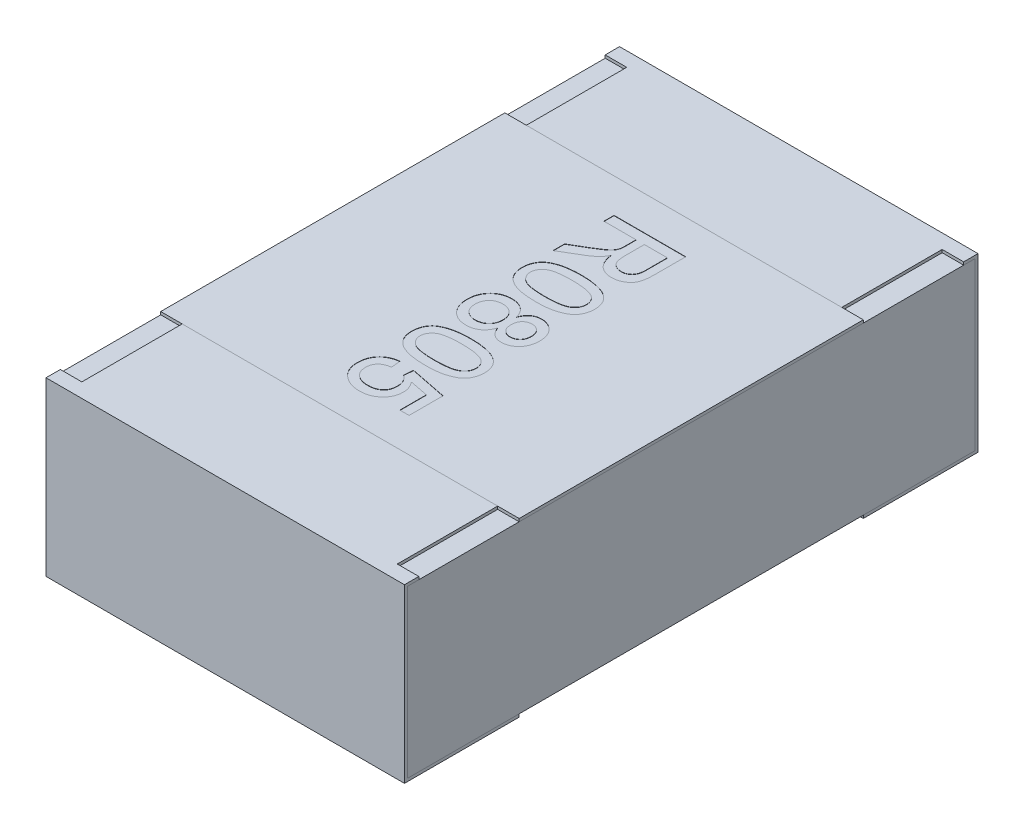
from build123d import *

# Parameters (mm, degrees)
BOSS_EXTRUDE2_DEPTH   = 0.625
BOSS_EXTRUDE2_2_DEPTH = 0.625
BOSS_EXTRUDE3_START   = -0.625
SKETCH5_W             = 1.98
SKETCH5_H             = 0.58
BOSS_EXTRUDE3_DEPTH   = 1.25
SKETCH6_W             = 0.075
SKETCH6_H             = 0.35
CUT_EXTRUDE1_DEPTH    = 0.01
SKETCH7_W             = 1.25
SKETCH7_H             = 1.2
BOSS_EXTRUDE4_DEPTH   = 0.01
TEXT0805_DEPTH        = 0.001


with BuildPart() as part:
    # Sketch4 → Boss-Extrude2 (new body, symmetric)
    with BuildSketch(Plane(origin=(0, 0, 0), x_dir=(0, 0, -1), z_dir=(1, 0, 0))):
        Polygon((-1, 0.3), (-1, -0.3), (-0.6, -0.3), (-0.6, -0.29), (-0.99, -0.29), (-0.99, 0.29), (-0.6, 0.29), (-0.6, 0.3), align=None)
    extrude(amount=BOSS_EXTRUDE2_DEPTH, both=True)


with BuildPart() as body_2:
    # Sketch4 → Boss-Extrude2 2 (new body, symmetric)
    with BuildSketch(Plane(origin=(0, 0, 0), x_dir=(0, 0, -1), z_dir=(1, 0, 0))):
        Polygon((0.6, 0.3), (1, 0.3), (1, -0.3), (0.6, -0.3), (0.6, -0.29), (0.99, -0.29), (0.99, 0.29), (0.6, 0.29), align=None)
    extrude(amount=BOSS_EXTRUDE2_2_DEPTH, both=True)


with BuildPart() as body_3:
    # Sketch5 → Boss-Extrude3 (new body)
    with BuildSketch(Plane(origin=(0, 0, 0), x_dir=(0, 0, -1), z_dir=(1, 0, 0)).offset(BOSS_EXTRUDE3_START)):
        Rectangle(SKETCH5_W, SKETCH5_H)
    extrude(amount=BOSS_EXTRUDE3_DEPTH)


with BuildPart() as cut_extrude1_tool:
    # Sketch6 → Cut-Extrude1 (new body)
    with BuildSketch(Plane(origin=(0, 0.3, 0), x_dir=(1, 0, 0), z_dir=(0, 1, 0))):
        with Locations((-0.5875, 0.775)):
            Rectangle(SKETCH6_W, SKETCH6_H)
        with Locations((0.5875, 0.775)):
            Rectangle(SKETCH6_W, SKETCH6_H)
        with Locations((0.5875, -0.775)):
            Rectangle(SKETCH6_W, SKETCH6_H)
        with Locations((-0.5875, -0.775)):
            Rectangle(SKETCH6_W, SKETCH6_H)
    extrude(amount=-CUT_EXTRUDE1_DEPTH)


with BuildPart() as part_1:
    add(part.part)

    # Cut-Extrude1: cut by cut_extrude1_tool
    add(cut_extrude1_tool.part, mode=Mode.SUBTRACT)


with BuildPart() as body_2_1:
    add(body_2.part)

    # Cut-Extrude1: cut by cut_extrude1_tool
    add(cut_extrude1_tool.part, mode=Mode.SUBTRACT)


with BuildPart() as body_4:
    # Sketch7 → Boss-Extrude4 (new body)
    with BuildSketch(Plane(origin=(0, 0.29, 0), x_dir=(1, 0, 0), z_dir=(0, 1, 0))):
        Rectangle(SKETCH7_W, SKETCH7_H)
    extrude(amount=BOSS_EXTRUDE4_DEPTH)

    # Sketch11 → TEXT0805 (cut)
    with BuildSketch(Plane(origin=(0, 0.3, 0), x_dir=(1, 0, 0), z_dir=(0, 1, 0))):
        with BuildLine():
            Line((-0.125, 0.480769231), (0.125, 0.480769231))
            Line((0.125, 0.480769231), (0.125, 0.372295673))
            add(Edge.make_bspline(
                [(0.125, 0.372295673), (0.124980081, 0.369741441), (0.124941531, 0.364798023), (0.124666062, 0.357629245), (0.124080828, 0.35095372), (0.123427193, 0.344729375), (0.122462088, 0.338966862), (0.121329846, 0.333663434), (0.119991666, 0.328839433), (0.118409887, 0.324458146), (0.116620913, 0.320392954), (0.114412437, 0.316625839), (0.111996411, 0.312995345), (0.109134976, 0.309645092), (0.106058159, 0.306428428), (0.102613855, 0.303455274), (0.098850706, 0.300711119), (0.093470755, 0.297325077), (0.08626914, 0.29376219), (0.077100416, 0.290721274), (0.067489381, 0.288777065), (0.060923489, 0.288567742), (0.057592147, 0.288461538)],
                knots=[0, 0, 0, 0, 7.663e-06, 1.4831e-05, 2.1514e-05, 2.7763e-05, 3.3601e-05, 3.9033e-05, 4.4027e-05, 4.8605e-05, 5.2999e-05, 5.7328e-05, 6.169e-05, 6.6063e-05, 7.0525e-05, 7.5034e-05, 7.9691e-05, 8.4485e-05, 9.4093e-05, 0.000103706, 0.0001134, 0.000123384, 0.000123384, 0.000123384, 0.000123384], degree=3))
            add(Edge.make_bspline(
                [(0.057592147, 0.288461538), (0.055453608, 0.288510459), (0.051229845, 0.288607082), (0.045019776, 0.289347208), (0.039086331, 0.290686435), (0.033377426, 0.292403638), (0.027974382, 0.294754309), (0.022765219, 0.297476233), (0.017899082, 0.300853001), (0.013213949, 0.304623586), (0.008918939, 0.309007151), (0.004956325, 0.313886761), (0.00153273, 0.319385225), (-0.001543983, 0.325401364), (-0.004236318, 0.331946092), (-0.006500007, 0.339062932), (-0.008272241, 0.346726684), (-0.009159985, 0.352041307), (-0.009615385, 0.354767628)],
                knots=[0, 0, 0, 0, 6.415e-06, 1.267e-05, 1.8722e-05, 2.4646e-05, 3.0525e-05, 3.6372e-05, 4.2248e-05, 4.8263e-05, 5.4389e-05, 6.0623e-05, 6.7083e-05, 7.378e-05, 8.0876e-05, 8.8288e-05, 9.616e-05, 0.000104451, 0.000104451, 0.000104451, 0.000104451], degree=3))
            add(Edge.make_bspline(
                [(-0.009615385, 0.354767628), (-0.010628144, 0.352752444), (-0.012544934, 0.348938421), (-0.015622195, 0.343677633), (-0.018667496, 0.339160094), (-0.020894326, 0.336554387), (-0.021935096, 0.335336538)],
                knots=[0, 0, 0, 0, 6.764e-06, 1.2802e-05, 1.8276e-05, 2.3078e-05, 2.3078e-05, 2.3078e-05, 2.3078e-05], degree=3))
            add(Edge.make_bspline(
                [(-0.021935096, 0.335336538), (-0.024247011, 0.332970873), (-0.028988368, 0.328119282), (-0.037139182, 0.321498652), (-0.046102745, 0.314947618), (-0.052634659, 0.311014514), (-0.055989583, 0.308994391)],
                knots=[0, 0, 0, 0, 9.916e-06, 2.0335e-05, 3.1455e-05, 4.3197e-05, 4.3197e-05, 4.3197e-05, 4.3197e-05], degree=3))
            Line((-0.055989583, 0.308994391), (-0.125, 0.267978766))
            Line((-0.125, 0.267978766), (-0.125, 0.308393429))
            Line((-0.125, 0.308393429), (-0.072215545, 0.339543269))
            add(Edge.make_bspline(
                [(-0.072215545, 0.339543269), (-0.07036357, 0.340663307), (-0.066774747, 0.342833757), (-0.061532932, 0.345968138), (-0.056708859, 0.349044075), (-0.052156321, 0.351887635), (-0.047993688, 0.354650924), (-0.044096778, 0.357178765), (-0.04061964, 0.359665648), (-0.036431824, 0.362557924), (-0.031873711, 0.366044983), (-0.027220525, 0.370141683), (-0.023421074, 0.373942975), (-0.019750609, 0.37869891), (-0.016330481, 0.384600378), (-0.014741028, 0.389606326), (-0.013972356, 0.392027244)],
                knots=[0, 0, 0, 0, 6.493e-06, 1.2582e-05, 1.8321e-05, 2.3656e-05, 2.8684e-05, 3.331e-05, 3.7589e-05, 4.1507e-05, 4.8579e-05, 5.4788e-05, 6.01e-05, 6.4668e-05, 7.2787e-05, 8.039e-05, 8.039e-05, 8.039e-05, 8.039e-05], degree=3))
            add(Edge.make_bspline(
                [(-0.013972356, 0.392027244), (-0.013789104, 0.393043422), (-0.013370736, 0.395363386), (-0.013097499, 0.399302681), (-0.012807494, 0.40407562), (-0.012815944, 0.407534649), (-0.012820513, 0.409405048)],
                knots=[0, 0, 0, 0, 3.096e-06, 7.067e-06, 1.1832e-05, 1.7441e-05, 1.7441e-05, 1.7441e-05, 1.7441e-05], degree=3))
            Line((-0.012820513, 0.409405048), (-0.012820513, 0.445512821))
            Line((-0.012820513, 0.445512821), (-0.125, 0.445512821))
            Line((-0.125, 0.445512821), (-0.125, 0.480769231))
        make_face()
        with BuildLine():
            Line((0.016025641, 0.445512821), (0.016025641, 0.378555689))
            add(Edge.make_bspline(
                [(0.016025641, 0.378555689), (0.016078383, 0.375198249), (0.016176978, 0.36892183), (0.017012973, 0.360144602), (0.018356033, 0.352650855), (0.0202836, 0.346300716), (0.022971837, 0.340968548), (0.026311873, 0.336387714), (0.030375799, 0.332490712), (0.03504878, 0.329305788), (0.04014749, 0.326797262), (0.045541227, 0.32508479), (0.051113312, 0.323891721), (0.054914825, 0.323776386), (0.056840946, 0.323717949)],
                knots=[0, 0, 0, 0, 1.0071e-05, 1.8826e-05, 2.6419e-05, 3.2881e-05, 3.8659e-05, 4.4248e-05, 4.9809e-05, 5.5463e-05, 6.1152e-05, 6.679e-05, 7.2407e-05, 7.8177e-05, 7.8177e-05, 7.8177e-05, 7.8177e-05], degree=3))
            add(Edge.make_bspline(
                [(0.056840946, 0.323717949), (0.058244232, 0.323764481), (0.060992858, 0.323855623), (0.065027077, 0.324333421), (0.068860518, 0.325262373), (0.072513445, 0.326489052), (0.075959102, 0.328128144), (0.079224189, 0.330075319), (0.082290611, 0.332398899), (0.085167707, 0.335060427), (0.087785584, 0.338116345), (0.090044243, 0.341606921), (0.091963617, 0.345504626), (0.09348696, 0.34981399), (0.094705386, 0.354521438), (0.095515966, 0.359653769), (0.096102499, 0.365187511), (0.096136411, 0.369022073), (0.096153846, 0.37099359)],
                knots=[0, 0, 0, 0, 4.211e-06, 8.249e-06, 1.216e-05, 1.6025e-05, 1.9788e-05, 2.3585e-05, 2.7411e-05, 3.1309e-05, 3.5323e-05, 3.9448e-05, 4.3749e-05, 4.8327e-05, 5.3137e-05, 5.8315e-05, 6.3901e-05, 6.9813e-05, 6.9813e-05, 6.9813e-05, 6.9813e-05], degree=3))
            Line((0.096153846, 0.37099359), (0.096153846, 0.445512821))
            Line((0.096153846, 0.445512821), (0.016025641, 0.445512821))
        make_face(mode=Mode.SUBTRACT)
        with BuildLine():
            add(Edge.make_bspline(
                [(-0.001702724, 0.243589744), (0.001870005, 0.243557452), (0.008867478, 0.243494206), (0.019106037, 0.243101913), (0.028829172, 0.242417), (0.038028443, 0.241394619), (0.0467246, 0.240183911), (0.05490528, 0.238610044), (0.062588678, 0.23683901), (0.069767331, 0.234714807), (0.076501073, 0.23237856), (0.082785669, 0.229736596), (0.088583945, 0.226737904), (0.094053366, 0.223652887), (0.098937729, 0.220061138), (0.103546409, 0.216418673), (0.107616333, 0.212352956), (0.111280719, 0.208057355), (0.114513306, 0.20346068), (0.117302904, 0.198589331), (0.119765846, 0.1934615), (0.121619965, 0.187979605), (0.12313146, 0.182257408), (0.124243336, 0.176250875), (0.124898824, 0.169953383), (0.124965894, 0.165649933), (0.125, 0.163461538)],
                knots=[0, 0, 0, 0, 1.0718e-05, 2.0992e-05, 3.0733e-05, 3.9952e-05, 4.8756e-05, 5.7065e-05, 6.4937e-05, 7.2401e-05, 7.9512e-05, 8.6312e-05, 9.2829e-05, 9.9091e-05, 0.000105122, 0.000110996, 0.000116698, 0.000122347, 0.000127918, 0.000133528, 0.000139173, 0.000144954, 0.000150858, 0.000156918, 0.000163262, 0.000169825, 0.000169825, 0.000169825, 0.000169825], degree=3))
            add(Edge.make_bspline(
                [(0.125, 0.163461538), (0.124905525, 0.160250936), (0.124719924, 0.15394358), (0.123208745, 0.144733828), (0.120617247, 0.136057958), (0.11714849, 0.127917328), (0.11266138, 0.120487963), (0.107346921, 0.113771127), (0.100982609, 0.108038207), (0.0937773, 0.103099832), (0.08571669, 0.098865176), (0.076876688, 0.095077102), (0.067219821, 0.091680741), (0.05860006, 0.089194753), (0.051146572, 0.087451855), (0.044987523, 0.086390729), (0.038362276, 0.085411003), (0.031254967, 0.08471656), (0.023698813, 0.084009907), (0.015660865, 0.083661024), (0.007146582, 0.083394775), (0.001302343, 0.083354198), (-0.001702724, 0.083333333)],
                knots=[0, 0, 0, 0, 9.628e-06, 1.8915e-05, 2.79e-05, 3.6738e-05, 4.5387e-05, 5.3865e-05, 6.2337e-05, 7.0978e-05, 8.0007e-05, 8.9608e-05, 9.9808e-05, 0.000110698, 0.000116505, 0.000122762, 0.000129441, 0.000136592, 0.000144182, 0.000152205, 0.000160722, 0.000169737, 0.000169737, 0.000169737, 0.000169737], degree=3))
            add(Edge.make_bspline(
                [(-0.001702724, 0.083333333), (-0.0052587, 0.083366048), (-0.012205999, 0.083429962), (-0.022362073, 0.083814273), (-0.032013225, 0.084531552), (-0.041171226, 0.085455872), (-0.049844567, 0.086700352), (-0.058012023, 0.088255808), (-0.065683611, 0.090052363), (-0.072867068, 0.09208541), (-0.079572281, 0.094450713), (-0.085831338, 0.097118462), (-0.09170557, 0.099979078), (-0.097085574, 0.103223793), (-0.10206041, 0.106679607), (-0.106645739, 0.110378807), (-0.110776391, 0.114398015), (-0.114428737, 0.118733712), (-0.117719455, 0.123297573), (-0.120534419, 0.128181581), (-0.122882805, 0.13337431), (-0.124845559, 0.138829479), (-0.126337213, 0.144583298), (-0.127444725, 0.150605786), (-0.12810623, 0.156936235), (-0.128171707, 0.161256427), (-0.128205128, 0.163461538)],
                knots=[0, 0, 0, 0, 1.0668e-05, 2.0842e-05, 3.0483e-05, 3.9697e-05, 4.8451e-05, 5.676e-05, 6.4632e-05, 7.2082e-05, 7.9146e-05, 8.5946e-05, 9.2485e-05, 9.8729e-05, 0.000104773, 0.000110647, 0.000116384, 0.000122033, 0.000127634, 0.000133243, 0.000138913, 0.00014471, 0.000150614, 0.000156724, 0.000163067, 0.000169681, 0.000169681, 0.000169681, 0.000169681], degree=3))
            add(Edge.make_bspline(
                [(-0.128205128, 0.163461538), (-0.12812266, 0.16635263), (-0.127961869, 0.171989463), (-0.126869393, 0.180221641), (-0.124946585, 0.18794798), (-0.122367828, 0.195233646), (-0.118918593, 0.201996746), (-0.114721924, 0.208269573), (-0.109875462, 0.214178172), (-0.106051714, 0.217579521), (-0.104116587, 0.219300881)],
                knots=[0, 0, 0, 0, 8.673e-06, 1.691e-05, 2.4854e-05, 3.2521e-05, 4.0047e-05, 4.7561e-05, 5.5134e-05, 6.2893e-05, 6.2893e-05, 6.2893e-05, 6.2893e-05], degree=3))
            add(Edge.make_bspline(
                [(-0.104116587, 0.219300881), (-0.101258496, 0.221282206), (-0.095364991, 0.225367783), (-0.085316019, 0.230149597), (-0.074253512, 0.234415059), (-0.061960424, 0.237762665), (-0.048534594, 0.240384675), (-0.03394968, 0.242278421), (-0.01821198, 0.243350095), (-0.007330039, 0.243508057), (-0.001702724, 0.243589744)],
                knots=[0, 0, 0, 0, 1.0418e-05, 2.1482e-05, 3.3275e-05, 4.596e-05, 5.9642e-05, 7.4289e-05, 9.0053e-05, 0.000106934, 0.000106934, 0.000106934, 0.000106934], degree=3))
        make_face()
        with BuildLine():
            add(Edge.make_bspline(
                [(-0.001602564, 0.211538462), (-0.006410973, 0.211506637), (-0.015615332, 0.211445718), (-0.028765347, 0.210809264), (-0.040628456, 0.209713633), (-0.051188232, 0.208265139), (-0.060458961, 0.206352539), (-0.068417018, 0.203951044), (-0.075157918, 0.201243988), (-0.080598111, 0.197894057), (-0.085032663, 0.194226253), (-0.088846521, 0.190439496), (-0.092088212, 0.186444697), (-0.094791122, 0.182267921), (-0.096837588, 0.177844362), (-0.098320871, 0.173222393), (-0.099174477, 0.168401005), (-0.099297124, 0.165117422), (-0.099358974, 0.163461538)],
                knots=[0, 0, 0, 0, 1.4424e-05, 2.7612e-05, 3.9482e-05, 5.0155e-05, 5.9574e-05, 6.7844e-05, 7.5071e-05, 8.1298e-05, 8.6922e-05, 9.2305e-05, 9.7396e-05, 0.000102328, 0.00010719, 0.000111973, 0.000116856, 0.000121823, 0.000121823, 0.000121823, 0.000121823], degree=3))
            add(Edge.make_bspline(
                [(-0.099358974, 0.163461538), (-0.099295773, 0.16180607), (-0.099170446, 0.158523308), (-0.098335662, 0.153690781), (-0.096776021, 0.149086794), (-0.094736783, 0.144669831), (-0.092095481, 0.140462697), (-0.088841545, 0.136487518), (-0.085029952, 0.132680813), (-0.080543857, 0.129029484), (-0.075078511, 0.125705076), (-0.068343103, 0.122947238), (-0.060371109, 0.120583169), (-0.051105103, 0.118660075), (-0.040562022, 0.117205605), (-0.028731817, 0.116116599), (-0.015598722, 0.115475885), (-0.006410995, 0.115415971), (-0.001602564, 0.115384615)],
                knots=[0, 0, 0, 0, 4.967e-06, 9.85e-06, 1.4648e-05, 1.951e-05, 2.4415e-05, 2.9507e-05, 3.4889e-05, 4.0552e-05, 4.6822e-05, 5.4003e-05, 6.232e-05, 7.174e-05, 8.2363e-05, 9.4234e-05, 0.000107371, 0.000121795, 0.000121795, 0.000121795, 0.000121795], degree=3))
            add(Edge.make_bspline(
                [(-0.001602564, 0.115384615), (0.003105819, 0.115414967), (0.012126904, 0.11547312), (0.025023578, 0.116130363), (0.036687586, 0.117160299), (0.047129588, 0.118569163), (0.05633854, 0.120441305), (0.064333139, 0.122712678), (0.071099127, 0.125417154), (0.07669585, 0.128639556), (0.08131576, 0.132212452), (0.085236709, 0.136008563), (0.088672768, 0.139954425), (0.091363273, 0.144275529), (0.093569875, 0.148788177), (0.095047046, 0.153589107), (0.095995083, 0.158616329), (0.096100151, 0.162054844), (0.096153846, 0.163812099)],
                knots=[0, 0, 0, 0, 1.4124e-05, 2.7061e-05, 3.8727e-05, 4.9245e-05, 5.8654e-05, 6.6895e-05, 7.4149e-05, 8.0454e-05, 8.6204e-05, 9.1623e-05, 9.681e-05, 0.000101853, 0.000106849, 0.000111838, 0.000116877, 0.000122144, 0.000122144, 0.000122144, 0.000122144], degree=3))
            add(Edge.make_bspline(
                [(0.096153846, 0.163812099), (0.096110388, 0.165467879), (0.096024696, 0.168732863), (0.095206757, 0.173513228), (0.093838982, 0.178043524), (0.091986197, 0.182375653), (0.089492715, 0.186401467), (0.086581397, 0.190280618), (0.083034282, 0.193831422), (0.080382513, 0.195971105), (0.079026442, 0.197065304)],
                knots=[0, 0, 0, 0, 4.964e-06, 9.789e-06, 1.4495e-05, 1.9137e-05, 2.3878e-05, 2.8666e-05, 3.3659e-05, 3.8885e-05, 3.8885e-05, 3.8885e-05, 3.8885e-05], degree=3))
            add(Edge.make_bspline(
                [(0.079026442, 0.197065304), (0.077034794, 0.198256554), (0.072828852, 0.200772221), (0.065518751, 0.203587107), (0.057164697, 0.206073666), (0.047638157, 0.208120928), (0.036955473, 0.209601978), (0.02512905, 0.210771211), (0.012142378, 0.211378583), (0.003105492, 0.211483698), (-0.001602564, 0.211538462)],
                knots=[0, 0, 0, 0, 6.951e-06, 1.4679e-05, 2.3409e-05, 3.3095e-05, 4.3874e-05, 5.5749e-05, 6.8736e-05, 8.2861e-05, 8.2861e-05, 8.2861e-05, 8.2861e-05], degree=3))
        make_face(mode=Mode.SUBTRACT)
        with BuildLine():
            add(Edge.make_bspline(
                [(0.012119391, 0.00380609), (0.01269909, 0.005367353), (0.013835412, 0.008427732), (0.015864898, 0.012775155), (0.017988986, 0.01685038), (0.020361222, 0.020578839), (0.022920717, 0.023981782), (0.025628265, 0.027115605), (0.028525648, 0.029917497), (0.032625581, 0.033209879), (0.038234929, 0.036591959), (0.045564597, 0.039612176), (0.053575195, 0.041318635), (0.059103354, 0.041548393), (0.061949119, 0.041666667)],
                knots=[0, 0, 0, 0, 4.994e-06, 9.79e-06, 1.4382e-05, 1.8773e-05, 2.3029e-05, 2.7147e-05, 3.1184e-05, 3.5103e-05, 4.2902e-05, 5.0741e-05, 5.8786e-05, 6.7321e-05, 6.7321e-05, 6.7321e-05, 6.7321e-05], degree=3))
            add(Edge.make_bspline(
                [(0.061949119, 0.041666667), (0.064139193, 0.041611545), (0.068438378, 0.04150334), (0.074747821, 0.040572291), (0.080789537, 0.039071766), (0.08657372, 0.036972712), (0.092056945, 0.034227298), (0.097320111, 0.030965008), (0.102279042, 0.027037441), (0.106898797, 0.022535711), (0.111182055, 0.017600005), (0.114879575, 0.012182461), (0.118009057, 0.006370693), (0.120563589, 0.00017618), (0.122583213, -0.006409302), (0.123954826, -0.013409063), (0.124828309, -0.020794594), (0.124941878, -0.025855487), (0.125, -0.028445513)],
                knots=[0, 0, 0, 0, 6.567e-06, 1.2892e-05, 1.9087e-05, 2.5218e-05, 3.131e-05, 3.7452e-05, 4.3764e-05, 5.0245e-05, 5.6779e-05, 6.3336e-05, 6.9879e-05, 7.6547e-05, 8.3407e-05, 9.0508e-05, 9.7918e-05, 0.000105687, 0.000105687, 0.000105687, 0.000105687], degree=3))
            add(Edge.make_bspline(
                [(0.125, -0.028445513), (0.124941265, -0.031052029), (0.124826857, -0.036129229), (0.123965422, -0.043554183), (0.122521604, -0.050597455), (0.120473189, -0.057254898), (0.117854168, -0.063537009), (0.114635047, -0.069402507), (0.110868919, -0.074911775), (0.106510873, -0.079923996), (0.101779453, -0.084484521), (0.0967105, -0.088435784), (0.091422295, -0.091824657), (0.085882711, -0.094625051), (0.080028668, -0.096696794), (0.073970458, -0.098275926), (0.067636097, -0.099191897), (0.063337574, -0.099302587), (0.061147837, -0.099358974)],
                knots=[0, 0, 0, 0, 7.818e-06, 1.5229e-05, 2.2389e-05, 2.9359e-05, 3.6093e-05, 4.2772e-05, 4.9398e-05, 5.6074e-05, 6.2662e-05, 6.9083e-05, 7.5321e-05, 8.148e-05, 8.7659e-05, 9.3914e-05, 0.000100239, 0.000106806, 0.000106806, 0.000106806, 0.000106806], degree=3))
            add(Edge.make_bspline(
                [(0.061147837, -0.099358974), (0.058399838, -0.099266998), (0.05301153, -0.099086648), (0.045240017, -0.097261668), (0.038009242, -0.094392715), (0.031360465, -0.090343846), (0.025401741, -0.085053494), (0.020153187, -0.078585023), (0.015599968, -0.070940099), (0.013310814, -0.065257349), (0.012119391, -0.062299679)],
                knots=[0, 0, 0, 0, 8.232e-06, 1.6141e-05, 2.3804e-05, 3.1491e-05, 3.9368e-05, 4.7588e-05, 5.6392e-05, 6.5947e-05, 6.5947e-05, 6.5947e-05, 6.5947e-05], degree=3))
            add(Edge.make_bspline(
                [(0.012119391, -0.062299679), (0.011486132, -0.064166238), (0.010245219, -0.067823882), (0.007827392, -0.072991525), (0.005245987, -0.077856371), (0.002377789, -0.082414173), (-0.000811827, -0.086599451), (-0.004308014, -0.090441098), (-0.008060229, -0.093962856), (-0.012130537, -0.097110196), (-0.016426954, -0.099923271), (-0.020965154, -0.102322634), (-0.025661352, -0.10439054), (-0.030598138, -0.106037727), (-0.035704671, -0.107415674), (-0.041059344, -0.108280955), (-0.046578672, -0.108854979), (-0.050329008, -0.108934152), (-0.052233574, -0.108974359)],
                knots=[0, 0, 0, 0, 5.909e-06, 1.1579e-05, 1.709e-05, 2.2426e-05, 2.7714e-05, 3.2855e-05, 3.7993e-05, 4.3132e-05, 4.8271e-05, 5.3379e-05, 5.8515e-05, 6.3646e-05, 6.8979e-05, 7.4363e-05, 7.99e-05, 8.5612e-05, 8.5612e-05, 8.5612e-05, 8.5612e-05], degree=3))
            add(Edge.make_bspline(
                [(-0.052233574, -0.108974359), (-0.054858381, -0.108910669), (-0.060029453, -0.108785195), (-0.067619915, -0.107682579), (-0.074911834, -0.106014647), (-0.081873258, -0.103581258), (-0.088513354, -0.100478035), (-0.094798012, -0.096626616), (-0.100791216, -0.092143901), (-0.106432415, -0.08703009), (-0.111499298, -0.081277709), (-0.116010417, -0.075100988), (-0.119770796, -0.068432243), (-0.122887601, -0.061357325), (-0.125302275, -0.053838294), (-0.126993274, -0.045885925), (-0.128000136, -0.037502557), (-0.128135882, -0.031770282), (-0.128205128, -0.028846154)],
                knots=[0, 0, 0, 0, 7.87e-06, 1.5505e-05, 2.2964e-05, 3.0281e-05, 3.7584e-05, 4.4911e-05, 5.2353e-05, 6.001e-05, 6.7708e-05, 7.5311e-05, 8.2914e-05, 9.0628e-05, 9.8468e-05, 0.000106562, 0.000114985, 0.000123756, 0.000123756, 0.000123756, 0.000123756], degree=3))
            add(Edge.make_bspline(
                [(-0.128205128, -0.028846154), (-0.128134392, -0.025922317), (-0.127995726, -0.02019061), (-0.127009414, -0.011799613), (-0.125241883, -0.003858516), (-0.122824315, 0.003650362), (-0.119793471, 0.010768875), (-0.11594243, 0.017387809), (-0.11147352, 0.023603512), (-0.10631221, 0.029272788), (-0.100673887, 0.034414208), (-0.094654208, 0.038955358), (-0.088267465, 0.042767183), (-0.081548187, 0.04591487), (-0.074471787, 0.048310377), (-0.067069103, 0.049992533), (-0.059344627, 0.051096998), (-0.054073749, 0.051219498), (-0.051382212, 0.051282051)],
                knots=[0, 0, 0, 0, 8.771e-06, 1.7194e-05, 2.5299e-05, 3.3138e-05, 4.0832e-05, 4.846e-05, 5.6063e-05, 6.3758e-05, 7.1415e-05, 7.8927e-05, 8.6339e-05, 9.3688e-05, 0.000101147, 0.000108703, 0.000116437, 0.000124508, 0.000124508, 0.000124508, 0.000124508], degree=3))
            add(Edge.make_bspline(
                [(-0.051382212, 0.051282051), (-0.049378145, 0.051238605), (-0.045445821, 0.051153356), (-0.039678396, 0.050631826), (-0.034180584, 0.049594766), (-0.028923938, 0.048251609), (-0.023874605, 0.04657047), (-0.019130745, 0.044400254), (-0.014623334, 0.041872917), (-0.010375603, 0.038982683), (-0.006424966, 0.035709314), (-0.002731152, 0.032161396), (0.00055556, 0.028215885), (0.003608555, 0.024022948), (0.006185309, 0.019396091), (0.008551026, 0.014512695), (0.010568264, 0.00928732), (0.01159717, 0.005651465), (0.012119391, 0.00380609)],
                knots=[0, 0, 0, 0, 6.013e-06, 1.1798e-05, 1.7348e-05, 2.2778e-05, 2.8067e-05, 3.329e-05, 3.8402e-05, 4.3555e-05, 4.8679e-05, 5.3779e-05, 5.8896e-05, 6.4065e-05, 6.9314e-05, 7.4757e-05, 8.0337e-05, 8.6089e-05, 8.6089e-05, 8.6089e-05, 8.6089e-05], degree=3))
        make_face()
        with BuildLine():
            add(Edge.make_bspline(
                [(0.061798878, 0.009615385), (0.060495731, 0.009586547), (0.057948075, 0.009530169), (0.054219589, 0.009089087), (0.050688509, 0.008267135), (0.047327484, 0.007179959), (0.044148049, 0.005753998), (0.041119708, 0.004064917), (0.038315435, 0.001989842), (0.035718639, -0.000360908), (0.03333419, -0.002969327), (0.031278449, -0.005902167), (0.029512989, -0.009104064), (0.028144416, -0.012605028), (0.026930821, -0.016315574), (0.02625274, -0.020364999), (0.025701414, -0.024657751), (0.02566149, -0.027625446), (0.025641026, -0.029146635)],
                knots=[0, 0, 0, 0, 3.909e-06, 7.642e-06, 1.1238e-05, 1.477e-05, 1.8223e-05, 2.1676e-05, 2.5152e-05, 2.8662e-05, 3.2173e-05, 3.573e-05, 3.9383e-05, 4.3112e-05, 4.6993e-05, 5.1069e-05, 5.5405e-05, 5.9965e-05, 5.9965e-05, 5.9965e-05, 5.9965e-05], degree=3))
            add(Edge.make_bspline(
                [(0.025641026, -0.029146635), (0.025662169, -0.03063428), (0.025703396, -0.033535106), (0.026244552, -0.037730686), (0.026962031, -0.04169775), (0.02807298, -0.045382182), (0.029449425, -0.0488331), (0.03126392, -0.051940734), (0.033226338, -0.054890044), (0.036371177, -0.058298996), (0.040796311, -0.061909659), (0.046787919, -0.065053809), (0.053365823, -0.067005103), (0.057945699, -0.067205058), (0.060296474, -0.067307692)],
                knots=[0, 0, 0, 0, 4.46e-06, 8.696e-06, 1.2674e-05, 1.654e-05, 2.0223e-05, 2.3789e-05, 2.7317e-05, 3.0827e-05, 3.7663e-05, 4.4339e-05, 5.1011e-05, 5.8048e-05, 5.8048e-05, 5.8048e-05, 5.8048e-05], degree=3))
            add(Edge.make_bspline(
                [(0.060296474, -0.067307692), (0.062729605, -0.067184315), (0.067490611, -0.066942899), (0.074325249, -0.064993087), (0.080515391, -0.061710407), (0.085035964, -0.0579604), (0.088310852, -0.054489651), (0.090395538, -0.051520248), (0.09216979, -0.048328129), (0.093618706, -0.044901144), (0.094787272, -0.041234338), (0.095553907, -0.037317778), (0.096091576, -0.033167921), (0.096132653, -0.030317055), (0.096153846, -0.028846154)],
                knots=[0, 0, 0, 0, 7.291e-06, 1.4266e-05, 2.1121e-05, 2.8168e-05, 3.1783e-05, 3.541e-05, 3.9019e-05, 4.2722e-05, 4.6555e-05, 5.0542e-05, 5.4679e-05, 5.9089e-05, 5.9089e-05, 5.9089e-05, 5.9089e-05], degree=3))
            add(Edge.make_bspline(
                [(0.096153846, -0.028846154), (0.096133333, -0.027375093), (0.096093343, -0.024507331), (0.095539611, -0.020330366), (0.094843795, -0.01637686), (0.093728417, -0.012682298), (0.092266626, -0.009265535), (0.090509244, -0.00609028), (0.088446204, -0.003164902), (0.085326174, 0.000330059), (0.080947968, 0.004039708), (0.075014807, 0.007257492), (0.06856883, 0.009253746), (0.06408348, 0.009493345), (0.061798878, 0.009615385)],
                knots=[0, 0, 0, 0, 4.41e-06, 8.596e-06, 1.2623e-05, 1.6442e-05, 2.0144e-05, 2.3753e-05, 2.731e-05, 3.0858e-05, 3.7789e-05, 4.44e-05, 5.0991e-05, 5.7833e-05, 5.7833e-05, 5.7833e-05, 5.7833e-05], degree=3))
        make_face(mode=Mode.SUBTRACT)
        with BuildLine():
            add(Edge.make_bspline(
                [(-0.05078125, 0.019230769), (-0.052837969, 0.019175689), (-0.056956823, 0.019065385), (-0.063071804, 0.018086556), (-0.069088196, 0.0164527), (-0.074959239, 0.014257081), (-0.080524259, 0.011290779), (-0.085452178, 0.007322142), (-0.089669433, 0.002395189), (-0.09313775, -0.003317372), (-0.095914827, -0.009501439), (-0.097863459, -0.015935671), (-0.099131517, -0.022469527), (-0.099283147, -0.026887293), (-0.099358974, -0.029096554)],
                knots=[0, 0, 0, 0, 6.167e-06, 1.2351e-05, 1.8522e-05, 2.4846e-05, 3.1121e-05, 3.7355e-05, 4.371e-05, 5.0479e-05, 5.7338e-05, 6.3992e-05, 7.0612e-05, 7.7235e-05, 7.7235e-05, 7.7235e-05, 7.7235e-05], degree=3))
            add(Edge.make_bspline(
                [(-0.099358974, -0.029096554), (-0.099328114, -0.030918407), (-0.09926816, -0.034457747), (-0.098583058, -0.039616997), (-0.097543536, -0.044478177), (-0.096118179, -0.049063556), (-0.094168202, -0.053305656), (-0.091889083, -0.057273501), (-0.089134664, -0.060926717), (-0.085990915, -0.064263471), (-0.082514314, -0.06725277), (-0.078760273, -0.069805099), (-0.074856366, -0.072059343), (-0.070647139, -0.073787112), (-0.066247417, -0.075203646), (-0.061617296, -0.076194569), (-0.056774438, -0.076815593), (-0.053470829, -0.07688673), (-0.051782853, -0.076923077)],
                knots=[0, 0, 0, 0, 5.462e-06, 1.0612e-05, 1.5582e-05, 2.0365e-05, 2.4982e-05, 2.9561e-05, 3.4068e-05, 3.8674e-05, 4.3291e-05, 4.7792e-05, 5.2276e-05, 5.6788e-05, 6.1412e-05, 6.6127e-05, 7.0972e-05, 7.6034e-05, 7.6034e-05, 7.6034e-05, 7.6034e-05], degree=3))
            add(Edge.make_bspline(
                [(-0.051782853, -0.076923077), (-0.050061743, -0.076885556), (-0.046692086, -0.076812095), (-0.041742935, -0.076206645), (-0.037031308, -0.075158686), (-0.032552602, -0.07367915), (-0.028263925, -0.071901835), (-0.02422898, -0.069632723), (-0.020483035, -0.066887741), (-0.016921285, -0.063868336), (-0.013696197, -0.060453971), (-0.01091531, -0.056682761), (-0.008459253, -0.052675019), (-0.006575265, -0.048309293), (-0.005066143, -0.043681822), (-0.003969594, -0.038770607), (-0.003299302, -0.033555627), (-0.003237126, -0.029983389), (-0.003205128, -0.028145032)],
                knots=[0, 0, 0, 0, 5.162e-06, 1.0107e-05, 1.493e-05, 1.9618e-05, 2.4241e-05, 2.8838e-05, 3.3466e-05, 3.8154e-05, 4.283e-05, 4.7518e-05, 5.219e-05, 5.6899e-05, 6.1745e-05, 6.6775e-05, 7.1974e-05, 7.7486e-05, 7.7486e-05, 7.7486e-05, 7.7486e-05], degree=3))
            add(Edge.make_bspline(
                [(-0.003205128, -0.028145032), (-0.003237499, -0.026356622), (-0.003300957, -0.022850781), (-0.003974271, -0.017757339), (-0.005012193, -0.012937), (-0.006512687, -0.008439303), (-0.00843275, -0.004218254), (-0.010797253, -0.000312396), (-0.013563742, 0.003334351), (-0.016770954, 0.006613311), (-0.02028219, 0.009548763), (-0.023969655, 0.012186418), (-0.027939232, 0.014337147), (-0.032078327, 0.016167643), (-0.036478589, 0.01749135), (-0.04104453, 0.01850815), (-0.045840111, 0.019121806), (-0.04911013, 0.019193917), (-0.05078125, 0.019230769)],
                knots=[0, 0, 0, 0, 5.362e-06, 1.0512e-05, 1.5384e-05, 2.0135e-05, 2.4707e-05, 2.9267e-05, 3.3805e-05, 3.8409e-05, 4.2994e-05, 4.7523e-05, 5.1984e-05, 5.6514e-05, 6.1076e-05, 6.5742e-05, 7.0538e-05, 7.555e-05, 7.555e-05, 7.555e-05, 7.555e-05], degree=3))
        make_face(mode=Mode.SUBTRACT)
        with BuildLine():
            add(Edge.make_bspline(
                [(-0.001702724, -0.141025641), (0.001870005, -0.141057933), (0.008867478, -0.141121179), (0.019106037, -0.141513471), (0.028829172, -0.142198384), (0.038028443, -0.143220766), (0.0467246, -0.144431474), (0.05490528, -0.146005341), (0.062588678, -0.147776375), (0.069767331, -0.149900578), (0.076501073, -0.152236824), (0.082785669, -0.154878789), (0.088583945, -0.157877481), (0.094053366, -0.160962498), (0.098937729, -0.164554247), (0.103546409, -0.168196712), (0.107616333, -0.172262429), (0.111280719, -0.176558029), (0.114513306, -0.181154705), (0.117302904, -0.186026053), (0.119765846, -0.191153885), (0.121619965, -0.19663578), (0.12313146, -0.202357976), (0.124243336, -0.20836451), (0.124898824, -0.214662001), (0.124965894, -0.218965452), (0.125, -0.221153846)],
                knots=[0, 0, 0, 0, 1.0718e-05, 2.0992e-05, 3.0733e-05, 3.9952e-05, 4.8756e-05, 5.7065e-05, 6.4937e-05, 7.2401e-05, 7.9512e-05, 8.6312e-05, 9.2829e-05, 9.9091e-05, 0.000105122, 0.000110996, 0.000116698, 0.000122347, 0.000127918, 0.000133528, 0.000139173, 0.000144954, 0.000150858, 0.000156918, 0.000163262, 0.000169825, 0.000169825, 0.000169825, 0.000169825], degree=3))
            add(Edge.make_bspline(
                [(0.125, -0.221153846), (0.124905525, -0.224364448), (0.124719924, -0.230671804), (0.123208745, -0.239881557), (0.120617247, -0.248557427), (0.11714849, -0.256698056), (0.11266138, -0.264127421), (0.107346921, -0.270844258), (0.100982609, -0.276577177), (0.0937773, -0.281515552), (0.08571669, -0.285750209), (0.076876688, -0.289538282), (0.067219821, -0.292934643), (0.05860006, -0.295420632), (0.051146572, -0.29716353), (0.044987523, -0.298224655), (0.038362276, -0.299204381), (0.031254967, -0.299898825), (0.023698813, -0.300605477), (0.015660865, -0.30095436), (0.007146582, -0.301220609), (0.001302343, -0.301261187), (-0.001702724, -0.301282051)],
                knots=[0, 0, 0, 0, 9.628e-06, 1.8915e-05, 2.79e-05, 3.6738e-05, 4.5387e-05, 5.3865e-05, 6.2337e-05, 7.0978e-05, 8.0007e-05, 8.9608e-05, 9.9808e-05, 0.000110698, 0.000116505, 0.000122762, 0.000129441, 0.000136592, 0.000144182, 0.000152205, 0.000160722, 0.000169737, 0.000169737, 0.000169737, 0.000169737], degree=3))
            add(Edge.make_bspline(
                [(-0.001702724, -0.301282051), (-0.0052587, -0.301249337), (-0.012205999, -0.301185423), (-0.022362073, -0.300801112), (-0.032013225, -0.300083832), (-0.041171226, -0.299159513), (-0.049844567, -0.297915033), (-0.058012023, -0.296359577), (-0.065683611, -0.294563022), (-0.072867068, -0.292529975), (-0.079572281, -0.290164672), (-0.085831338, -0.287496922), (-0.09170557, -0.284636307), (-0.097085574, -0.281391592), (-0.10206041, -0.277935778), (-0.106645739, -0.274236578), (-0.110776391, -0.27021737), (-0.114428737, -0.265881673), (-0.117719455, -0.261317811), (-0.120534419, -0.256433803), (-0.122882805, -0.251241075), (-0.124845559, -0.245785905), (-0.126337213, -0.240032087), (-0.127444725, -0.234009599), (-0.12810623, -0.22767915), (-0.128171707, -0.223358957), (-0.128205128, -0.221153846)],
                knots=[0, 0, 0, 0, 1.0668e-05, 2.0842e-05, 3.0483e-05, 3.9697e-05, 4.8451e-05, 5.676e-05, 6.4632e-05, 7.2082e-05, 7.9146e-05, 8.5946e-05, 9.2485e-05, 9.8729e-05, 0.000104773, 0.000110647, 0.000116384, 0.000122033, 0.000127634, 0.000133243, 0.000138913, 0.00014471, 0.000150614, 0.000156724, 0.000163067, 0.000169681, 0.000169681, 0.000169681, 0.000169681], degree=3))
            add(Edge.make_bspline(
                [(-0.128205128, -0.221153846), (-0.12812266, -0.218262755), (-0.127961869, -0.212625922), (-0.126869393, -0.204393743), (-0.124946585, -0.196667405), (-0.122367828, -0.189381739), (-0.118918593, -0.182618638), (-0.114721924, -0.176345812), (-0.109875462, -0.170437212), (-0.106051714, -0.167035863), (-0.104116587, -0.165314503)],
                knots=[0, 0, 0, 0, 8.673e-06, 1.691e-05, 2.4854e-05, 3.2521e-05, 4.0047e-05, 4.7561e-05, 5.5134e-05, 6.2893e-05, 6.2893e-05, 6.2893e-05, 6.2893e-05], degree=3))
            add(Edge.make_bspline(
                [(-0.104116587, -0.165314503), (-0.101258496, -0.163333178), (-0.095364991, -0.159247601), (-0.085316019, -0.154465788), (-0.074253512, -0.150200325), (-0.061960424, -0.146852719), (-0.048534594, -0.144230709), (-0.03394968, -0.142336964), (-0.01821198, -0.14126529), (-0.007330039, -0.141107327), (-0.001702724, -0.141025641)],
                knots=[0, 0, 0, 0, 1.0418e-05, 2.1482e-05, 3.3275e-05, 4.596e-05, 5.9642e-05, 7.4289e-05, 9.0053e-05, 0.000106934, 0.000106934, 0.000106934, 0.000106934], degree=3))
        make_face()
        with BuildLine():
            add(Edge.make_bspline(
                [(-0.001602564, -0.173076923), (-0.006410973, -0.173108747), (-0.015615332, -0.173169666), (-0.028765347, -0.173806121), (-0.040628456, -0.174901751), (-0.051188232, -0.176350246), (-0.060458961, -0.178262846), (-0.068417018, -0.180664341), (-0.075157918, -0.183371397), (-0.080598111, -0.186721327), (-0.085032663, -0.190389132), (-0.088846521, -0.194175889), (-0.092088212, -0.198170688), (-0.094791122, -0.202347464), (-0.096837588, -0.206771022), (-0.098320871, -0.211392992), (-0.099174477, -0.216214379), (-0.099297124, -0.219497963), (-0.099358974, -0.221153846)],
                knots=[0, 0, 0, 0, 1.4424e-05, 2.7612e-05, 3.9482e-05, 5.0155e-05, 5.9574e-05, 6.7844e-05, 7.5071e-05, 8.1298e-05, 8.6922e-05, 9.2305e-05, 9.7396e-05, 0.000102328, 0.00010719, 0.000111973, 0.000116856, 0.000121823, 0.000121823, 0.000121823, 0.000121823], degree=3))
            add(Edge.make_bspline(
                [(-0.099358974, -0.221153846), (-0.099295773, -0.222809315), (-0.099170446, -0.226092076), (-0.098335662, -0.230924604), (-0.096776021, -0.23552859), (-0.094736783, -0.239945553), (-0.092095481, -0.244152687), (-0.088841545, -0.248127867), (-0.085029952, -0.251934572), (-0.080543857, -0.2555859), (-0.075078511, -0.258910309), (-0.068343103, -0.261668146), (-0.060371109, -0.264032215), (-0.051105103, -0.26595531), (-0.040562022, -0.26740978), (-0.028731817, -0.268498786), (-0.015598722, -0.2691395), (-0.006410995, -0.269199413), (-0.001602564, -0.269230769)],
                knots=[0, 0, 0, 0, 4.967e-06, 9.85e-06, 1.4648e-05, 1.951e-05, 2.4415e-05, 2.9507e-05, 3.4889e-05, 4.0552e-05, 4.6822e-05, 5.4003e-05, 6.232e-05, 7.174e-05, 8.2363e-05, 9.4234e-05, 0.000107371, 0.000121795, 0.000121795, 0.000121795, 0.000121795], degree=3))
            add(Edge.make_bspline(
                [(-0.001602564, -0.269230769), (0.003105819, -0.269200418), (0.012126904, -0.269142265), (0.025023578, -0.268485021), (0.036687586, -0.267455086), (0.047129588, -0.266046222), (0.05633854, -0.26417408), (0.064333139, -0.261902707), (0.071099127, -0.259198231), (0.07669585, -0.255975828), (0.08131576, -0.252402932), (0.085236709, -0.248606822), (0.088672768, -0.244660959), (0.091363273, -0.240339856), (0.093569875, -0.235827207), (0.095047046, -0.231026277), (0.095995083, -0.225999056), (0.096100151, -0.22256054), (0.096153846, -0.220803285)],
                knots=[0, 0, 0, 0, 1.4124e-05, 2.7061e-05, 3.8727e-05, 4.9245e-05, 5.8654e-05, 6.6895e-05, 7.4149e-05, 8.0454e-05, 8.6204e-05, 9.1623e-05, 9.681e-05, 0.000101853, 0.000106849, 0.000111838, 0.000116877, 0.000122144, 0.000122144, 0.000122144, 0.000122144], degree=3))
            add(Edge.make_bspline(
                [(0.096153846, -0.220803285), (0.096110388, -0.219147506), (0.096024696, -0.215882521), (0.095206757, -0.211102156), (0.093838982, -0.20657186), (0.091986197, -0.202239731), (0.089492715, -0.198213918), (0.086581397, -0.194334767), (0.083034282, -0.190783963), (0.080382513, -0.188644279), (0.079026442, -0.18755008)],
                knots=[0, 0, 0, 0, 4.964e-06, 9.789e-06, 1.4495e-05, 1.9137e-05, 2.3878e-05, 2.8666e-05, 3.3659e-05, 3.8885e-05, 3.8885e-05, 3.8885e-05, 3.8885e-05], degree=3))
            add(Edge.make_bspline(
                [(0.079026442, -0.18755008), (0.077034794, -0.186358831), (0.072828852, -0.183843163), (0.065518751, -0.181028278), (0.057164697, -0.178541719), (0.047638157, -0.176494457), (0.036955473, -0.175013406), (0.02512905, -0.173844174), (0.012142378, -0.173236801), (0.003105492, -0.173131686), (-0.001602564, -0.173076923)],
                knots=[0, 0, 0, 0, 6.951e-06, 1.4679e-05, 2.3409e-05, 3.3095e-05, 4.3874e-05, 5.5749e-05, 6.8736e-05, 8.2861e-05, 8.2861e-05, 8.2861e-05, 8.2861e-05], degree=3))
        make_face(mode=Mode.SUBTRACT)
        with BuildLine():
            Line((-0.057692308, -0.333333333), (-0.054487179, -0.365384615))
            add(Edge.make_bspline(
                [(-0.054487179, -0.365384615), (-0.056293093, -0.365701973), (-0.059805877, -0.366319284), (-0.064890735, -0.367495638), (-0.06961471, -0.369023386), (-0.074018715, -0.37073998), (-0.078056182, -0.372780442), (-0.081790862, -0.374991298), (-0.085090184, -0.377598552), (-0.088126707, -0.380339729), (-0.09080242, -0.383348381), (-0.093058139, -0.386653538), (-0.095026117, -0.390162984), (-0.09663741, -0.393919464), (-0.097816792, -0.397928733), (-0.09874948, -0.402139766), (-0.099219457, -0.406606787), (-0.099311874, -0.409654605), (-0.099358974, -0.411207933)],
                knots=[0, 0, 0, 0, 5.501e-06, 1.07e-05, 1.5641e-05, 2.0384e-05, 2.4863e-05, 2.92e-05, 3.3378e-05, 3.7454e-05, 4.1463e-05, 4.5422e-05, 4.9435e-05, 5.3519e-05, 5.7654e-05, 6.1956e-05, 6.6441e-05, 7.1103e-05, 7.1103e-05, 7.1103e-05, 7.1103e-05], degree=3))
            add(Edge.make_bspline(
                [(-0.099358974, -0.411207933), (-0.09931293, -0.413113518), (-0.099222888, -0.416839972), (-0.098461349, -0.422261258), (-0.09720566, -0.427382101), (-0.095448416, -0.432178), (-0.093263076, -0.436705176), (-0.090433458, -0.440813444), (-0.087252688, -0.444726809), (-0.0834606, -0.448193445), (-0.079332279, -0.451349058), (-0.07482604, -0.454072589), (-0.070005133, -0.456365417), (-0.064870482, -0.458295728), (-0.059392754, -0.459721121), (-0.05360109, -0.460769614), (-0.047491801, -0.461442704), (-0.043304412, -0.46150609), (-0.041165865, -0.461538462)],
                knots=[0, 0, 0, 0, 5.715e-06, 1.1175e-05, 1.6386e-05, 2.1503e-05, 2.6475e-05, 3.142e-05, 3.6434e-05, 4.1572e-05, 4.6791e-05, 5.2004e-05, 5.7335e-05, 6.2786e-05, 6.8435e-05, 7.4289e-05, 8.0434e-05, 8.6847e-05, 8.6847e-05, 8.6847e-05, 8.6847e-05], degree=3))
            add(Edge.make_bspline(
                [(-0.041165865, -0.461538462), (-0.039127858, -0.461501668), (-0.035159385, -0.461430023), (-0.029380628, -0.460826654), (-0.023946848, -0.459808698), (-0.018798155, -0.45849156), (-0.014015003, -0.45667605), (-0.009528041, -0.454522753), (-0.005432497, -0.451884874), (-0.001600849, -0.44895006), (0.001834068, -0.445598131), (0.004734421, -0.441783804), (0.007272816, -0.437656713), (0.009331295, -0.433133734), (0.010860668, -0.428212203), (0.012037383, -0.422941027), (0.012656287, -0.41726551), (0.012764788, -0.413362661), (0.012820513, -0.411358173)],
                knots=[0, 0, 0, 0, 6.113e-06, 1.1904e-05, 1.7404e-05, 2.2688e-05, 2.7823e-05, 3.2728e-05, 3.7591e-05, 4.2409e-05, 4.719e-05, 5.1938e-05, 5.6748e-05, 6.17e-05, 6.68e-05, 7.2183e-05, 7.788e-05, 8.3895e-05, 8.3895e-05, 8.3895e-05, 8.3895e-05], degree=3))
            add(Edge.make_bspline(
                [(0.012820513, -0.411358173), (0.012745693, -0.408866087), (0.012601713, -0.404070364), (0.011447392, -0.39719644), (0.009519384, -0.39095184), (0.006700565, -0.385398473), (0.00331583, -0.380426042), (-0.000512063, -0.375942799), (-0.004782906, -0.371912466), (-0.007998266, -0.369701645), (-0.009615385, -0.368589744)],
                knots=[0, 0, 0, 0, 7.473e-06, 1.438e-05, 2.0842e-05, 2.7001e-05, 3.2988e-05, 3.8849e-05, 4.4661e-05, 5.0541e-05, 5.0541e-05, 5.0541e-05, 5.0541e-05], degree=3))
            Line((-0.009615385, -0.368589744), (-0.006410256, -0.336538462))
            Line((-0.006410256, -0.336538462), (0.121794872, -0.362179487))
            Line((0.121794872, -0.362179487), (0.121794872, -0.480769231))
            Line((0.121794872, -0.480769231), (0.08974359, -0.480769231))
            Line((0.08974359, -0.480769231), (0.08974359, -0.388371394))
            Line((0.08974359, -0.388371394), (0.024989984, -0.375651042))
            add(Edge.make_bspline(
                [(0.024989984, -0.375651042), (0.026316898, -0.377419625), (0.028922747, -0.380892843), (0.032338044, -0.386309072), (0.035197426, -0.391794323), (0.037590865, -0.397319748), (0.03939198, -0.402961949), (0.040679924, -0.408659453), (0.041539095, -0.414420466), (0.041624022, -0.418282878), (0.041666667, -0.420222356)],
                knots=[0, 0, 0, 0, 6.631e-06, 1.3023e-05, 1.9183e-05, 2.5173e-05, 3.1065e-05, 3.6921e-05, 4.2686e-05, 4.85e-05, 4.85e-05, 4.85e-05, 4.85e-05], degree=3))
            add(Edge.make_bspline(
                [(0.041666667, -0.420222356), (0.041600531, -0.422746529), (0.041470295, -0.427717239), (0.040400237, -0.435041749), (0.038583749, -0.442045222), (0.036137181, -0.44878255), (0.032893924, -0.45516505), (0.028966705, -0.461256775), (0.024324661, -0.467035426), (0.019049564, -0.472459447), (0.013218921, -0.477399432), (0.006928074, -0.481728967), (0.000221066, -0.485412708), (-0.006894363, -0.488414618), (-0.014430903, -0.490730291), (-0.022346444, -0.492357414), (-0.030671981, -0.493391554), (-0.036355053, -0.493522662), (-0.039262821, -0.493589744)],
                knots=[0, 0, 0, 0, 7.57e-06, 1.4908e-05, 2.2147e-05, 2.9245e-05, 3.6367e-05, 4.3577e-05, 5.0952e-05, 5.8567e-05, 6.6242e-05, 7.3841e-05, 8.1439e-05, 8.9159e-05, 9.6968e-05, 0.000105052, 0.000113375, 0.000122096, 0.000122096, 0.000122096, 0.000122096], degree=3))
            add(Edge.make_bspline(
                [(-0.039262821, -0.493589744), (-0.042036442, -0.493533519), (-0.047515136, -0.49342246), (-0.055586289, -0.492496228), (-0.063378331, -0.49100984), (-0.070855233, -0.48888319), (-0.078083126, -0.486244085), (-0.084972873, -0.48290041), (-0.09166126, -0.479077562), (-0.095782425, -0.476005351), (-0.097856571, -0.474459135)],
                knots=[0, 0, 0, 0, 8.319e-06, 1.6432e-05, 2.4338e-05, 3.2091e-05, 3.9729e-05, 4.7389e-05, 5.5042e-05, 6.2797e-05, 6.2797e-05, 6.2797e-05, 6.2797e-05], degree=3))
            add(Edge.make_bspline(
                [(-0.097856571, -0.474459135), (-0.100277944, -0.472495307), (-0.105041047, -0.468632246), (-0.111223268, -0.461943398), (-0.116477306, -0.454752792), (-0.120745831, -0.447017636), (-0.124175952, -0.438789857), (-0.126458569, -0.429968381), (-0.127991436, -0.420659799), (-0.128132917, -0.414269277), (-0.128205128, -0.411007612)],
                knots=[0, 0, 0, 0, 9.343e-06, 1.8379e-05, 2.7234e-05, 3.5999e-05, 4.4825e-05, 5.3899e-05, 6.3277e-05, 7.3053e-05, 7.3053e-05, 7.3053e-05, 7.3053e-05], degree=3))
            add(Edge.make_bspline(
                [(-0.128205128, -0.411007612), (-0.128150551, -0.408317259), (-0.128043786, -0.403054388), (-0.127115754, -0.395348563), (-0.125635561, -0.388019584), (-0.123513581, -0.381064358), (-0.120828509, -0.374464811), (-0.117437988, -0.368299296), (-0.113511394, -0.362485884), (-0.108999881, -0.357099641), (-0.104021714, -0.352127001), (-0.098528968, -0.347777527), (-0.092673327, -0.343952505), (-0.086472096, -0.340601246), (-0.079803167, -0.337992438), (-0.07280035, -0.33580825), (-0.065394519, -0.334188608), (-0.060286631, -0.333621414), (-0.057692308, -0.333333333)],
                knots=[0, 0, 0, 0, 8.068e-06, 1.5784e-05, 2.3248e-05, 3.0472e-05, 3.7568e-05, 4.4583e-05, 5.1542e-05, 5.8582e-05, 6.5629e-05, 7.2613e-05, 7.9559e-05, 8.6593e-05, 9.3717e-05, 0.000101003, 0.000108587, 0.000116413, 0.000116413, 0.000116413, 0.000116413], degree=3))
        make_face()
    extrude(amount=-TEXT0805_DEPTH, mode=Mode.SUBTRACT)


solid = Compound([body_3.part, part_1.part, body_2_1.part, body_4.part])
